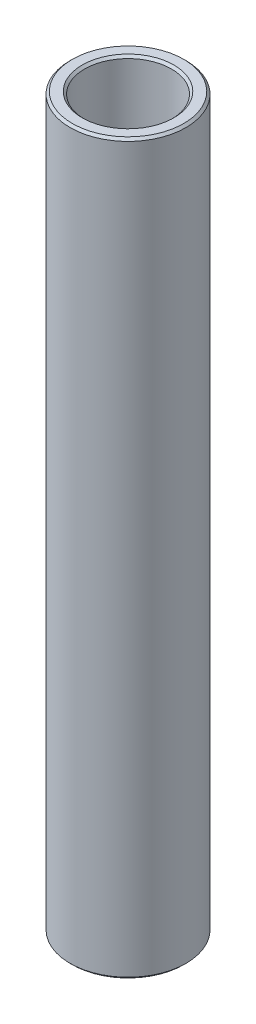
from build123d import *

# Parameters (mm, degrees)
SKETCH1_W     = 1.5875
SKETCH1_H     = 79.771875
CHAMFER1_SIZE = 0.254


with BuildPart() as part:
    # Sketch1 → Revolve1 (revolve)
    with BuildSketch(Plane.XY):
        with Locations((5.55625, 110.529632465)):
            Rectangle(SKETCH1_W, SKETCH1_H)
    revolve(axis=Axis((0, 61.118694965, 0), (0, 1, 0)))

    # Chamfer1
    chamfer1_edges = [part.edges().sort_by_distance(p)[0] for p in [
        (-6.35, 70.643694965, 0),
        (-6.35, 150.415569965, 0),
        (-4.7625, 150.415569965, 0),
        (-4.7625, 70.643694965, 0),
    ]]
    chamfer(chamfer1_edges, length=CHAMFER1_SIZE)


solid = part.part
